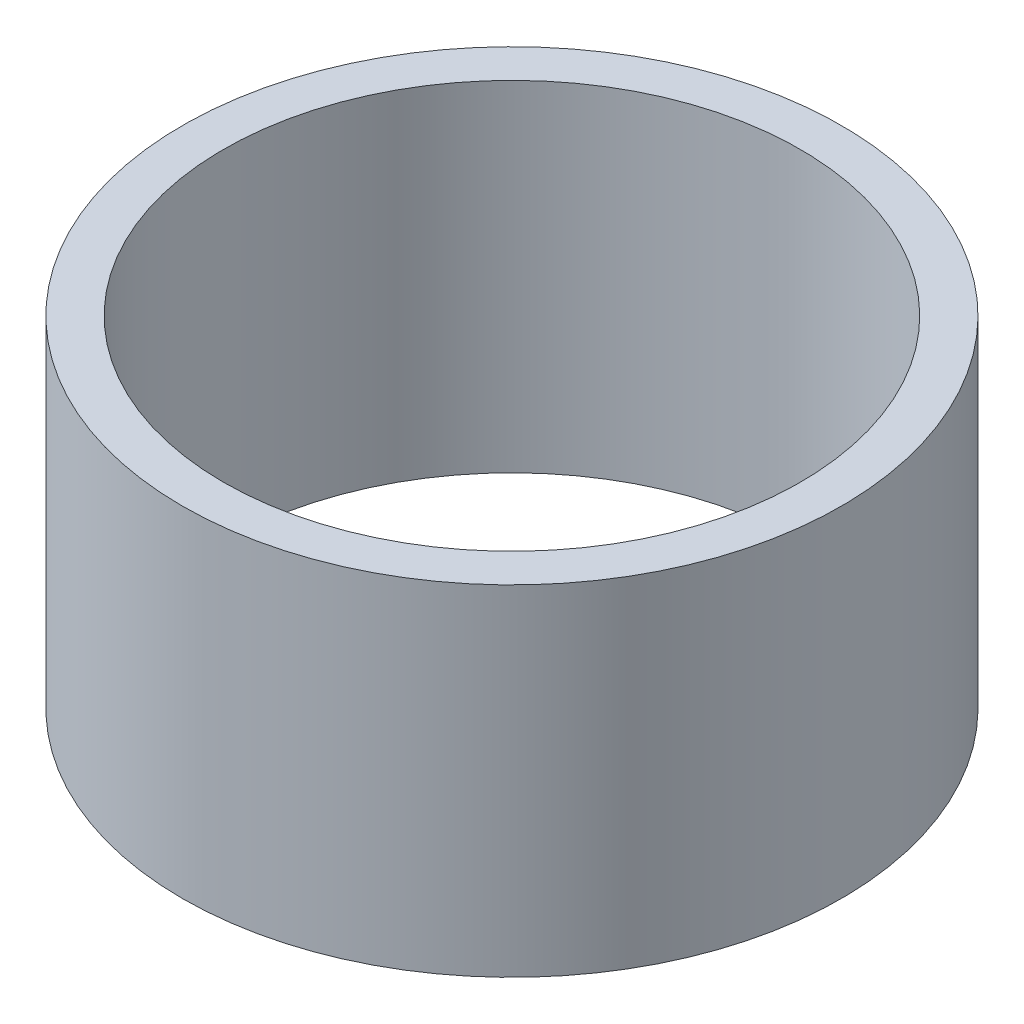
from build123d import *

# Parameters (mm, degrees)
SKETCH1_R           = 32
SKETCH1_R_2         = 28
BOSS_EXTRUDE1_DEPTH = 33


with BuildPart() as part:
    # Sketch1 → Boss-Extrude1 (new body)
    with BuildSketch(Plane(origin=(0, 0, 0), x_dir=(1, 0, 0), z_dir=(0, 1, 0))):
        Circle(SKETCH1_R)
        Circle(SKETCH1_R_2, mode=Mode.SUBTRACT)
    extrude(amount=BOSS_EXTRUDE1_DEPTH)


solid = part.part
